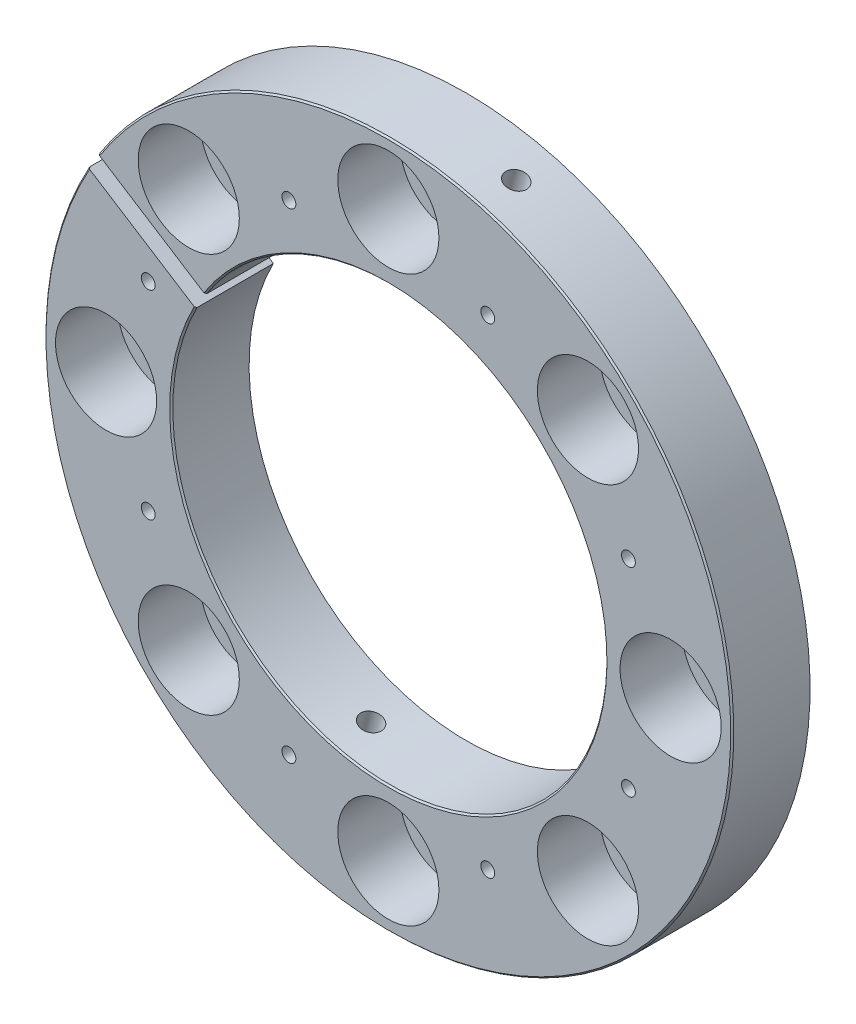
from build123d import *

# Parameters (mm, degrees)
SKETCH2_R                                 = 56.134
BOSS_EXTRUDE1_DEPTH                       = 12.7
SKETCH3_R                                 = 35.433
CUT_EXTRUDE1_DEPTH                        = 81.394912227
CHAMFER1_SIZE                             = 0.254
CBORE_FOR_5_16_HEX_HEAD_BOLT2_D           = 8.4328
CBORE_FOR_5_16_HEX_HEAD_BOLT2_CBORE_D     = 16.51
CBORE_FOR_5_16_HEX_HEAD_BOLT2_CBORE_DEPTH = 10.16
CIRPATTERN1_COUNT                         = 8
CIRPATTERN2_COUNT                         = 8
CUT_EXTRUDE2_DEPTH                        = 81.394912227
F_8_32_TAPPED_HOLE2_D                     = 3.4544


with BuildPart() as part:
    # Sketch2 → Boss-Extrude1 (new body)
    with BuildSketch(Plane.XY):
        Circle(SKETCH2_R)
    extrude(amount=BOSS_EXTRUDE1_DEPTH)

    # Sketch3 → Cut-Extrude1 (cut, through all)
    with BuildSketch(Plane.XY.offset(12.7)):
        Circle(SKETCH3_R)
    extrude(amount=-CUT_EXTRUDE1_DEPTH, mode=Mode.SUBTRACT)

    # Chamfer1
    chamfer1_edges = [part.edges().sort_by_distance(p)[0] for p in [
        (-56.134, 0, 12.7),
        (-35.433, 0, 12.7),
    ]]
    chamfer(chamfer1_edges, length=CHAMFER1_SIZE)

    # CBORE for 5_16 Hex Head Bolt2 (through all)
    with Locations(Plane.XY.offset(12.7)):
        with Locations((0, 46.0756)):
            cbore_for_5_16_hex_head_bolt2 = CounterBoreHole(CBORE_FOR_5_16_HEX_HEAD_BOLT2_D / 2, CBORE_FOR_5_16_HEX_HEAD_BOLT2_CBORE_D / 2, CBORE_FOR_5_16_HEX_HEAD_BOLT2_CBORE_DEPTH)

    # CirPattern1: CBORE for 5_16 Hex Head Bolt2 ×8 about axis
    cirpattern1_axis = Axis((0, 0, 0), (0, 0, 1))
    for i in range(1, CIRPATTERN1_COUNT):
        add(cbore_for_5_16_hex_head_bolt2.rotate(cirpattern1_axis, i * 360 / CIRPATTERN1_COUNT), mode=Mode.SUBTRACT)

    # Sketch21 → 4-40 Tapped Hole1 (revolve, cut)
    with BuildSketch(Plane(origin=(-16.232665834, 39.18912201, 12.7), x_dir=(0, -1, 0), z_dir=(1, 0, 0))):
        Polygon((0, 0), (0, 8.273752758), (1.1303, 7.5946), (1.1303, 0), align=None)
    f_4_40_tapped_hole1 = revolve(axis=Axis((-16.232665834, 39.18912201, 19.05), (0, 0, -1)), mode=Mode.SUBTRACT)

    # CirPattern2: 4-40 Tapped Hole1 ×8 about axis
    cirpattern2_axis = Axis((0, 0, 0), (0, 0, 1))
    for i in range(1, CIRPATTERN2_COUNT):
        add(f_4_40_tapped_hole1.rotate(cirpattern2_axis, i * 360 / CIRPATTERN2_COUNT), mode=Mode.SUBTRACT)

    # Sketch26 → Cut-Extrude2 (cut, through all)
    with BuildSketch(Plane.XY.offset(12.7)):
        Polygon((0, 0), (-58.152698702, 37.047354929), (-59.858624959, 34.369587088), (-1.705926257, -2.67776784), align=None)
    extrude(amount=-CUT_EXTRUDE2_DEPTH, mode=Mode.SUBTRACT)

    # 8-32 Tapped Hole2 (through all)
    with Locations(Plane(origin=(14.528548278, 54.221280333, 6.35), x_dir=(0.965925826289, -0.258819045103, 0), z_dir=(0.258819045103, 0.965925826289, 0))):
        with Locations((0, 0)):
            Hole(F_8_32_TAPPED_HOLE2_D / 2)


solid = part.part
